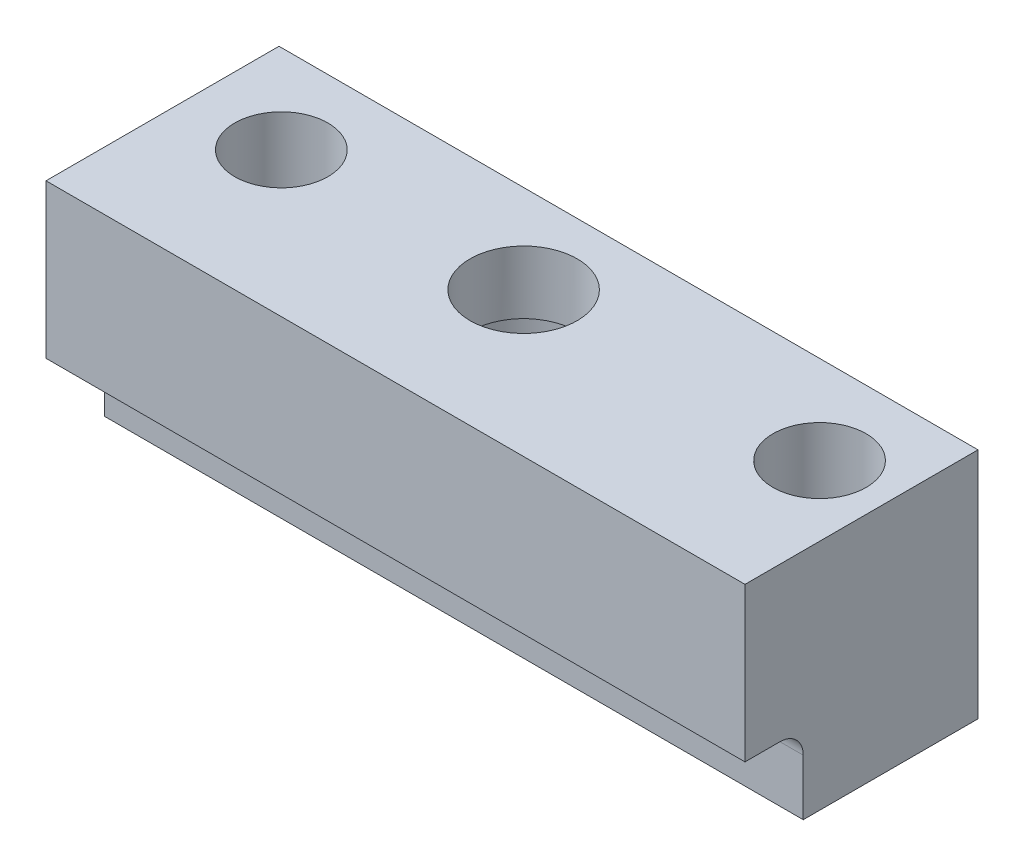
from build123d import *

# Parameters (mm, degrees)
BOSS_EXTRUDE1_DEPTH      = 39.878
BOSS_EXTRUDE1_DEPTH_BACK = 36.322
FILLET1_R                = 2.54
SKETCH2_R                = 5.08
SKETCH2_R_2              = 5.842
CUT_EXTRUDE1_DEPTH       = 26.4
SKETCH3_R                = 7.366
CUT_EXTRUDE2_DEPTH       = 18.542


with BuildPart() as part:
    # Sketch1 → Boss-Extrude1 (new body, two sides)
    with BuildSketch(Plane(origin=(0, 0, 0), x_dir=(0, 0, -1), z_dir=(1, 0, 0))) as boss_extrude1_sk:
        Polygon((0, 0), (-6.35, 0), (-6.35, 16.764), (19.05, 16.764), (19.05, -8.636), (0, -8.636), align=None)
    extrude(amount=BOSS_EXTRUDE1_DEPTH)
    extrude(boss_extrude1_sk.sketch, amount=-BOSS_EXTRUDE1_DEPTH_BACK)

    # Fillet1
    fillet1_edges = [part.edges().sort_by_distance(p)[0] for p in [
        (1.778, 0, 0),
    ]]
    fillet(fillet1_edges, radius=FILLET1_R)

    # Sketch2 → Cut-Extrude1 (cut, through all)
    with BuildSketch(Plane(origin=(0, 16.764, 0), x_dir=(1, 0, 0), z_dir=(0, 1, 0))):
        with Locations((-26.416, 9.398)):
            Circle(SKETCH2_R)
        with Locations((32.258, 9.398)):
            Circle(SKETCH2_R)
        with Locations((0, 9.398)):
            Circle(SKETCH2_R_2)
    extrude(amount=-CUT_EXTRUDE1_DEPTH, mode=Mode.SUBTRACT)

    # Sketch3 → Cut-Extrude2 (cut)
    with BuildSketch(Plane.XZ.offset(8.636)):
        with Locations((0, -9.398)):
            Circle(SKETCH3_R)
    extrude(amount=-CUT_EXTRUDE2_DEPTH, mode=Mode.SUBTRACT)


solid = part.part
